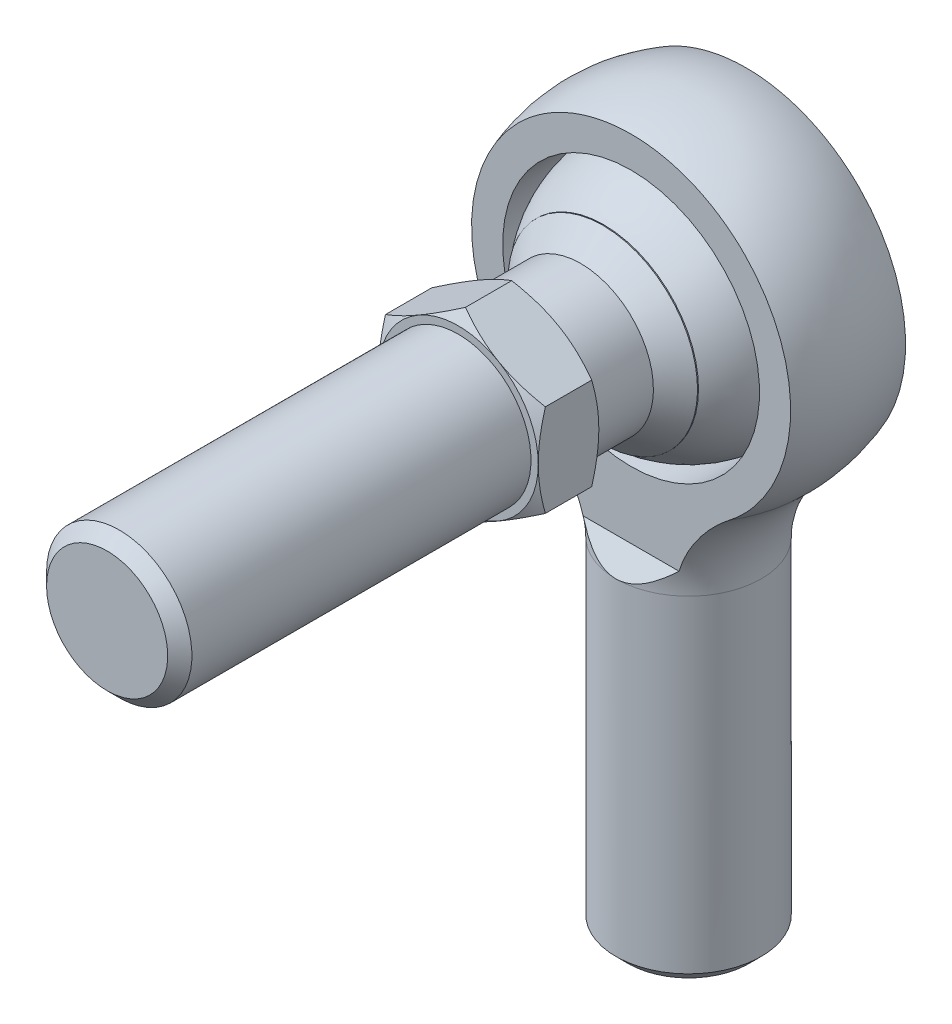
from build123d import *

# Parameters (mm, degrees)
SKETCH1_W               = 9.525
SKETCH1_H               = 44.45
CHAMFER2_SIZE           = 1.5875
CUT_EXTRUDE1_DEPTH      = 60.737268518
CUT_EXTRUDE1_DEPTH_BACK = 60.737268518
CUT_EXTRUDE2_DEPTH      = 57.261143358
CUT_EXTRUDE2_DEPTH_BACK = 57.261143358
SKETCH6_R               = 16.829024
CUT_EXTRUDE3_DEPTH      = 58.898412748
CUT_EXTRUDE3_DEPTH_BACK = 58.898412748
SKETCH8_W               = 11.1125
SKETCH8_H               = 50.8
CUT_EXTRUDE4_DEPTH      = 58.898412748
CUT_EXTRUDE4_DEPTH_BACK = 58.898412748
SKETCH10_R              = 9.525
CHAMFER1_SIZE           = 0.9525
SKETCH12_W              = 41.275
SKETCH12_H              = 9.525
CHAMFER3_SIZE           = 1.5875
SKETCH15_W              = 46.0375
SKETCH15_H              = 9.525
EXTRUDE1_DEPTH          = 7.9375
SKETCH17_OUTSIDE_W      = 329.402
SKETCH17_OUTSIDE_H      = 380.202
SKETCH17_OUTSIDE_R      = 10.4775
CUT_EXTRUDE5_DEPTH      = 73.583409942
CUT_EXTRUDE5_DRAFT      = -60
SKETCH18_OUTSIDE_W      = 345.992
SKETCH18_OUTSIDE_H      = 396.792
SKETCH18_OUTSIDE_R      = 10.4775
CUT_EXTRUDE6_DEPTH      = 78.372607855
CUT_EXTRUDE6_DRAFT      = -60


with BuildPart() as part:
    # Sketch1 → Revolve1 (revolve)
    with BuildSketch(Plane.XY, mode=Mode.PRIVATE) as revolve1_sk:
        with Locations((4.7625, -22.225)):
            Rectangle(SKETCH1_W, SKETCH1_H)
    revolve(revolve1_sk.sketch.rotate(Axis((0, 50.8, 0), (0, -1, 0)), 180), axis=Axis((0, 50.8, 0), (0, -1, 0)))

    # Chamfer2
    chamfer2_edges = [part.edges().sort_by_distance(p)[0] for p in [
        (9.525, -44.45, 0),
    ]]
    chamfer(chamfer2_edges, length=CHAMFER2_SIZE)

    # Sketch4 → Revolve2 (revolve)
    with BuildSketch(Plane.XY):
        with BuildLine():
            Line((9.525, 0), (0, 0))
            Line((0, 0), (0, 50.8))
            ThreePointArc((0, 50.8), (20.743606098, 36.553310038), (14.893041237, 12.078092784))
            ThreePointArc((14.893041237, 12.078092784), (10.927447707, 6.608634352), (9.525, 0))
        make_face()
    revolve(axis=Axis((0, 50.8, 0), (0, 1, 0)))

    # Sketch5 → Cut-Extrude1 (cut, two sides: drawn at the far end of the back side and taken through both)
    with BuildSketch(Plane(origin=(0, 0, 0), x_dir=(0, 0, -1), z_dir=(1, 0, 0)).offset(-CUT_EXTRUDE1_DEPTH_BACK)):
        Polygon((7.5311, 50.8), (22.225, 50.8), (22.225, 0), (9.525, 0), (7.5311, 3.01244), align=None)
        Polygon((-7.5311, 50.8), (-7.5311, 3.01244), (-9.525, 0), (-22.225, 0), (-22.225, 50.8), align=None)
    extrude(amount=CUT_EXTRUDE1_DEPTH + CUT_EXTRUDE1_DEPTH_BACK, mode=Mode.SUBTRACT)

    # Sketch6 → Cut-Extrude2 (cut, two sides: drawn at the far end of the back side and taken through both)
    with BuildSketch(Plane.XY.offset(-CUT_EXTRUDE2_DEPTH_BACK)):
        with Locations(Location((0, 28.575, 0), (0, 0, 270))):
            Circle(SKETCH6_R)
    extrude(amount=CUT_EXTRUDE2_DEPTH + CUT_EXTRUDE2_DEPTH_BACK, mode=Mode.SUBTRACT)


with BuildPart() as body_2:
    # Sketch7 → Revolve3 (revolve)
    with BuildSketch(Plane.XY):
        with BuildLine():
            Line((0, 45.2374), (0, 11.9126))
            ThreePointArc((0, 11.9126), (16.6624, 28.575), (0, 45.2374))
        make_face()
    revolve(axis=Axis((0, 0, 0), (0, 1, 0)))

    # Sketch8 → Cut-Extrude3 (cut, two sides: drawn at the far end of the back side and taken through both)
    with BuildSketch(Plane(origin=(0, 0, 0), x_dir=(0, 0, -1), z_dir=(1, 0, 0)).offset(-CUT_EXTRUDE3_DEPTH_BACK)):
        with Locations((-16.66875, 25.4)):
            Rectangle(SKETCH8_W, SKETCH8_H)
        with Locations((16.66875, 25.4)):
            Rectangle(SKETCH8_W, SKETCH8_H)
    extrude(amount=CUT_EXTRUDE3_DEPTH + CUT_EXTRUDE3_DEPTH_BACK, mode=Mode.SUBTRACT)

    # Sketch10 → Cut-Extrude4 (cut, two sides: drawn at the far end of the back side and taken through both)
    with BuildSketch(Plane.XY.offset(-CUT_EXTRUDE4_DEPTH_BACK)):
        with Locations((0, 28.575)):
            Circle(SKETCH10_R)
    extrude(amount=CUT_EXTRUDE4_DEPTH + CUT_EXTRUDE4_DEPTH_BACK, mode=Mode.SUBTRACT)

    # Chamfer1
    chamfer1_edges = [body_2.edges().sort_by_distance(p)[0] for p in [
        (-9.525, 28.575, -11.1125),
        (-9.525, 28.575, 11.1125),
    ]]
    chamfer(chamfer1_edges, length=CHAMFER1_SIZE)


with BuildPart() as body_3:
    # Sketch12 → Revolve4 (revolve)
    with BuildSketch(Plane(origin=(0, 0, 0), x_dir=(0, 0, -1), z_dir=(1, 0, 0)), mode=Mode.PRIVATE) as revolve4_sk:
        with Locations((-55.5625, 33.3375)):
            Rectangle(SKETCH12_W, SKETCH12_H)
    revolve(revolve4_sk.sketch.rotate(Axis((0, 28.575, -11.1125), (0, 0, -1)), 180), axis=Axis((0, 28.575, -11.1125), (0, 0, -1)))

    # Chamfer3
    chamfer3_edges = [body_3.edges().sort_by_distance(p)[0] for p in [
        (0, 38.1, 76.2),
    ]]
    chamfer(chamfer3_edges, length=CHAMFER3_SIZE)

    # Sketch15 → Revolve5 (revolve)
    with BuildSketch(Plane(origin=(0, 0, 0), x_dir=(0, 0, -1), z_dir=(1, 0, 0)), mode=Mode.PRIVATE) as revolve5_sk:
        with Locations((-11.90625, 33.3375)):
            Rectangle(SKETCH15_W, SKETCH15_H)
    revolve(revolve5_sk.sketch.rotate(Axis((0, 28.575, -11.1125), (0, 0, -1)), 180), axis=Axis((0, 28.575, -11.1125), (0, 0, -1)))

    # Sketch16 → Extrude1 (add)
    with BuildSketch(Plane.XY.offset(30.1752)):
        Polygon((0, 40.673374891), (-10.4775, 34.624187445), (-10.4775, 22.525812555), (0, 16.476625109), (10.4775, 22.525812555), (10.4775, 34.624187445), align=None)
    extrude(amount=-EXTRUDE1_DEPTH)


with BuildPart() as cut_extrude5_tool:
    # Sketch17 outside → Cut-Extrude5 (with draft: the straight prism first)
    with BuildSketch(Plane.XY.offset(30.1752)):
        with Locations((0, 3.175)):
            Rectangle(SKETCH17_OUTSIDE_W, SKETCH17_OUTSIDE_H)
        with Locations((0, 28.575)):
            Circle(SKETCH17_OUTSIDE_R, mode=Mode.SUBTRACT)
    extrude(amount=-CUT_EXTRUDE5_DEPTH)
    # Cut-Extrude5: the draft: its side faces are tilted about the plane it starts from
    cut_extrude5_sides = [cut_extrude5_tool.faces().sort_by_distance(p)[0] for p in [
        (0, -186.926, -6.616504971),
        (164.701, 3.175, -6.616504971),
        (0, 193.276, -6.616504971),
        (-164.701, 3.175, -6.616504971),
        (-10.4775, 28.575, -6.616504971),
    ]]
    draft(cut_extrude5_sides, Plane.XY.offset(30.1752), CUT_EXTRUDE5_DRAFT)


with BuildPart() as body_3_1:
    add(body_3.part)

    # Cut-Extrude5: cut by cut_extrude5_tool
    add(cut_extrude5_tool.part, mode=Mode.SUBTRACT)


with BuildPart() as cut_extrude6_tool:
    # Sketch18 outside → Cut-Extrude6 (with draft: the straight prism first)
    with BuildSketch(Plane(origin=(0, 0, 22.2377), x_dir=(-1, 0, 0), z_dir=(0, 0, -1))):
        with Locations((0, 3.175)):
            Rectangle(SKETCH18_OUTSIDE_W, SKETCH18_OUTSIDE_H)
        with Locations((0, 28.575)):
            Circle(SKETCH18_OUTSIDE_R, mode=Mode.SUBTRACT)
    extrude(amount=-CUT_EXTRUDE6_DEPTH)
    # Cut-Extrude6: the draft: its side faces are tilted about the plane it starts from
    cut_extrude6_sides = [cut_extrude6_tool.faces().sort_by_distance(p)[0] for p in [
        (0, -195.221, 61.424003928),
        (-172.996, 3.175, 61.424003928),
        (0, 201.571, 61.424003928),
        (172.996, 3.175, 61.424003928),
        (10.4775, 28.575, 61.424003928),
    ]]
    draft(cut_extrude6_sides, Plane(origin=(0, 0, 22.2377), x_dir=(-1, 0, 0), z_dir=(0, 0, -1)), CUT_EXTRUDE6_DRAFT)


with BuildPart() as body_3_2:
    add(body_3_1.part)

    # Cut-Extrude6: cut by cut_extrude6_tool
    add(cut_extrude6_tool.part, mode=Mode.SUBTRACT)

    # Sketch20 → Revolve6 (revolve)
    with BuildSketch(Plane(origin=(0, 0, 0), x_dir=(0, 0, -1), z_dir=(1, 0, 0)), mode=Mode.PRIVATE) as revolve6_sk:
        Polygon((-11.2395, 40.990631982), (-14.130131982, 38.1), (-11.2395, 38.1), align=None)
    revolve(revolve6_sk.sketch.rotate(Axis((0, 28.575, -11.1125), (0, 0, 1)), 90), axis=Axis((0, 28.575, -11.1125), (0, 0, 1)))


solid = Compound([part.part, body_2.part, body_3_2.part])
